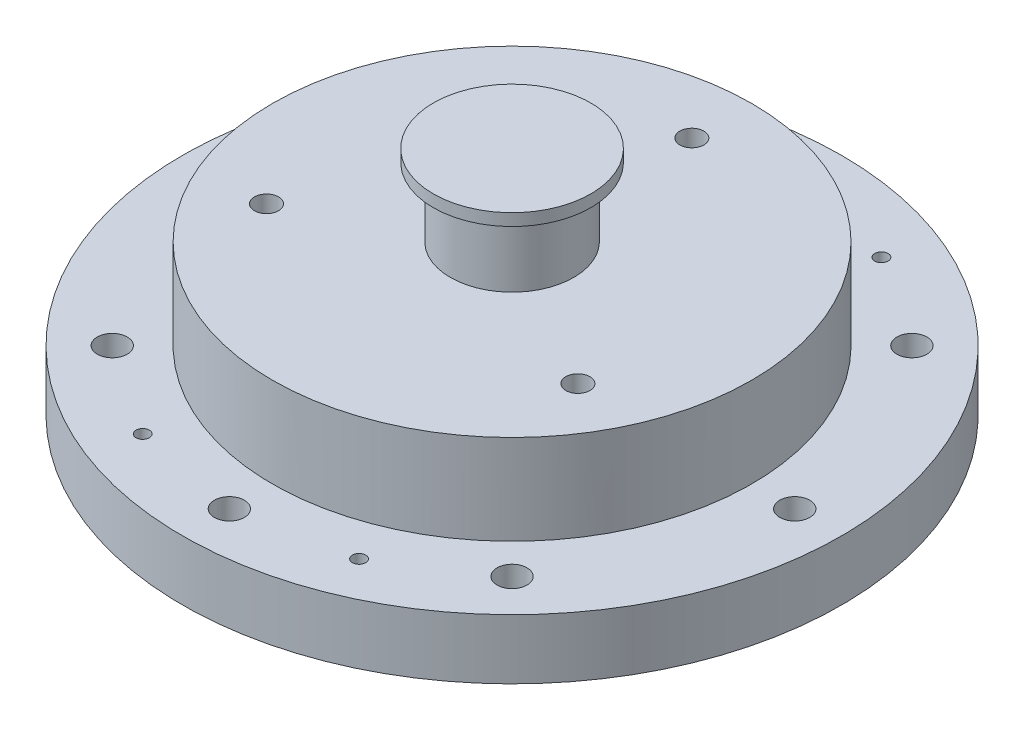
from build123d import *

# Parameters (mm, degrees)
SKETCH1_R                        = 50.8
BOSS_EXTRUDE1_DEPTH              = 25.4
SKETCH2_R                        = 69.85
SKETCH2_R_2                      = 50.8
BOSS_EXTRUDE2_DEPTH              = 12.7
CUT_EXTRUDE2_REACH               = 27.4
SKETCH4_R                        = 3.175
SKETCH5_R                        = 12.827
CUT_EXTRUDE3_DEPTH               = 19.05
CUT_EXTRUDE4_REACH               = 8.35
SKETCH6_R                        = 1.5875
SKETCH34_R                       = 13.081
SKETCH34_R_2                     = 4.7625
BOSS_EXTRUDE3_DEPTH              = 19.05
SKETCH40_R                       = 50.8
BOSS_EXTRUDE5_DEPTH              = 6.35
SKETCH38_R                       = 6.2484
BOSS_EXTRUDE4_DEPTH              = 1.905
SKETCH39_R                       = 4.7625
CUT_EXTRUDE7_DEPTH               = 6.35
SKETCH41_R                       = 4.7625
CUT_EXTRUDE8_DEPTH               = 6.35
SKETCH42_R                       = 23.7871
CUT_EXTRUDE9_DEPTH               = 6.477
F_10_24_TAPPED_HOLE1_AT_2_COUNT  = 2
F_10_24_TAPPED_HOLE1_AT_2_PITCH  = 24.695704333
F_10_24_TAPPED_HOLE1_AT_3_COUNT  = 2
F_10_24_TAPPED_HOLE1_AT_3_PITCH  = 34.925
F_10_24_TAPPED_HOLE1_AT_4_COUNT  = 2
F_10_24_TAPPED_HOLE1_AT_4_PITCH  = 24.695704333
SKETCH46_R                       = 3.175
CUT_EXTRUDE10_DEPTH              = 6.35
F_1_4_20_TAPPED_HOLE1_AT_2_COUNT = 2
F_1_4_20_TAPPED_HOLE1_AT_2_PITCH = 65.991135768
F_1_4_20_TAPPED_HOLE1_AT_3_COUNT = 2
F_1_4_20_TAPPED_HOLE1_AT_3_PITCH = 65.991135768
CUT_EXTRUDE11_START              = 6.477
SKETCH49_R                       = 23.8252
CUT_EXTRUDE11_DEPTH              = 3.937
SKETCH50_R                       = 1.4097
CUT_EXTRUDE12_DEPTH              = 41.005
SKETCH51_R                       = 16.693981068
BOSS_EXTRUDE6_DEPTH              = 2.54


with BuildPart() as part:
    # Sketch1 → Boss-Extrude1 (new body)
    with BuildSketch(Plane(origin=(0, 0, 0), x_dir=(1, 0, 0), z_dir=(0, 1, 0))):
        Circle(SKETCH1_R)
    extrude(amount=BOSS_EXTRUDE1_DEPTH)

    # Sketch2 → Boss-Extrude2 (add)
    with BuildSketch(Plane.XZ):
        Circle(SKETCH2_R)
        Circle(SKETCH2_R_2, mode=Mode.SUBTRACT)
    extrude(amount=-BOSS_EXTRUDE2_DEPTH)

    # Sketch4 → Cut-Extrude2 (cut, up to next)
    with BuildSketch(Plane.XZ, mode=Mode.PRIVATE) as cut_extrude2_sk1:
        with Locations((0, -59.9186)):
            Circle(SKETCH4_R)
    cut_extrude2_tool1 = extrude(cut_extrude2_sk1.sketch, amount=-CUT_EXTRUDE2_REACH, mode=Mode.PRIVATE) & part.part
    add(cut_extrude2_tool1.solids().sort_by_distance((0, 0, -59.9186))[0], mode=Mode.SUBTRACT)
    # Sketch4 → Cut-Extrude2 (cut, up to next)
    with BuildSketch(Plane.XZ, mode=Mode.PRIVATE) as cut_extrude2_sk2:
        with Locations((-42.368848379, -42.368848379)):
            Circle(SKETCH4_R)
    cut_extrude2_tool2 = extrude(cut_extrude2_sk2.sketch, amount=-CUT_EXTRUDE2_REACH, mode=Mode.PRIVATE) & part.part
    add(cut_extrude2_tool2.solids().sort_by_distance((-42.368848, 0, -42.368848))[0], mode=Mode.SUBTRACT)
    # Sketch4 → Cut-Extrude2 (cut, up to next)
    with BuildSketch(Plane.XZ, mode=Mode.PRIVATE) as cut_extrude2_sk3:
        with Locations((-59.9186, 0)):
            Circle(SKETCH4_R)
    cut_extrude2_tool3 = extrude(cut_extrude2_sk3.sketch, amount=-CUT_EXTRUDE2_REACH, mode=Mode.PRIVATE) & part.part
    add(cut_extrude2_tool3.solids().sort_by_distance((-59.9186, 0, 0))[0], mode=Mode.SUBTRACT)
    # Sketch4 → Cut-Extrude2 (cut, up to next)
    with BuildSketch(Plane.XZ, mode=Mode.PRIVATE) as cut_extrude2_sk4:
        with Locations((-42.368848379, 42.368848379)):
            Circle(SKETCH4_R)
    cut_extrude2_tool4 = extrude(cut_extrude2_sk4.sketch, amount=-CUT_EXTRUDE2_REACH, mode=Mode.PRIVATE) & part.part
    add(cut_extrude2_tool4.solids().sort_by_distance((-42.368848, 0, 42.368848))[0], mode=Mode.SUBTRACT)
    # Sketch4 → Cut-Extrude2 (cut, up to next)
    with BuildSketch(Plane.XZ, mode=Mode.PRIVATE) as cut_extrude2_sk5:
        with Locations((0, 59.9186)):
            Circle(SKETCH4_R)
    cut_extrude2_tool5 = extrude(cut_extrude2_sk5.sketch, amount=-CUT_EXTRUDE2_REACH, mode=Mode.PRIVATE) & part.part
    add(cut_extrude2_tool5.solids().sort_by_distance((0, 0, 59.9186))[0], mode=Mode.SUBTRACT)
    # Sketch4 → Cut-Extrude2 (cut, up to next)
    with BuildSketch(Plane.XZ, mode=Mode.PRIVATE) as cut_extrude2_sk6:
        with Locations((42.368848379, 42.368848379)):
            Circle(SKETCH4_R)
    cut_extrude2_tool6 = extrude(cut_extrude2_sk6.sketch, amount=-CUT_EXTRUDE2_REACH, mode=Mode.PRIVATE) & part.part
    add(cut_extrude2_tool6.solids().sort_by_distance((42.368848, 0, 42.368848))[0], mode=Mode.SUBTRACT)
    # Sketch4 → Cut-Extrude2 (cut, up to next)
    with BuildSketch(Plane.XZ, mode=Mode.PRIVATE) as cut_extrude2_sk7:
        with Locations((59.9186, 0)):
            Circle(SKETCH4_R)
    cut_extrude2_tool7 = extrude(cut_extrude2_sk7.sketch, amount=-CUT_EXTRUDE2_REACH, mode=Mode.PRIVATE) & part.part
    add(cut_extrude2_tool7.solids().sort_by_distance((59.9186, 0, 0))[0], mode=Mode.SUBTRACT)
    # Sketch4 → Cut-Extrude2 (cut, up to next)
    with BuildSketch(Plane.XZ, mode=Mode.PRIVATE) as cut_extrude2_sk8:
        with Locations((42.368848379, -42.368848379)):
            Circle(SKETCH4_R)
    cut_extrude2_tool8 = extrude(cut_extrude2_sk8.sketch, amount=-CUT_EXTRUDE2_REACH, mode=Mode.PRIVATE) & part.part
    add(cut_extrude2_tool8.solids().sort_by_distance((42.368848, 0, -42.368848))[0], mode=Mode.SUBTRACT)

    # Sketch5 → Cut-Extrude3 (cut)
    with BuildSketch(Plane(origin=(0, 25.4, 0), x_dir=(1, 0, 0), z_dir=(0, 1, 0))):
        Circle(SKETCH5_R)
    extrude(amount=-CUT_EXTRUDE3_DEPTH, mode=Mode.SUBTRACT)

    # Sketch6 → Cut-Extrude4 (cut, up to next)
    with BuildSketch(Plane(origin=(0, 6.35, 0), x_dir=(1, 0, 0), z_dir=(0, 1, 0)), mode=Mode.PRIVATE) as cut_extrude4_sk1:
        Circle(SKETCH6_R)
    cut_extrude4_tool1 = extrude(cut_extrude4_sk1.sketch, amount=-CUT_EXTRUDE4_REACH, mode=Mode.PRIVATE) & part.part
    add(cut_extrude4_tool1.solids().sort_by_distance((0, 6.35, 0))[0], mode=Mode.SUBTRACT)

    # Sketch34 → Boss-Extrude3 (add)
    with BuildSketch(Plane(origin=(0, 25.4, 0), x_dir=(1, 0, 0), z_dir=(0, 1, 0))):
        Circle(SKETCH34_R)
        Circle(SKETCH34_R_2, mode=Mode.SUBTRACT)
    extrude(amount=BOSS_EXTRUDE3_DEPTH)

    # Sketch40 → Boss-Extrude5 (add)
    with BuildSketch(Plane(origin=(0, 25.4, 0), x_dir=(1, 0, 0), z_dir=(0, 1, 0))):
        Circle(SKETCH40_R)
    extrude(amount=BOSS_EXTRUDE5_DEPTH)

    # Sketch41 → Cut-Extrude8 (cut)
    with BuildSketch(Plane(origin=(0, 31.75, 0), x_dir=(1, 0, 0), z_dir=(0, 1, 0))):
        Circle(SKETCH41_R)
    extrude(amount=-CUT_EXTRUDE8_DEPTH, mode=Mode.SUBTRACT)

    # Sketch42 → Cut-Extrude9 (cut)
    with BuildSketch(Plane.XZ):
        Circle(SKETCH42_R)
    extrude(amount=-CUT_EXTRUDE9_DEPTH, mode=Mode.SUBTRACT)

    # Sketch45 → #10-24 Tapped Hole1 (revolve, cut)
    with BuildSketch(Plane(origin=(0, 6.477, 17.4625), x_dir=(0, 0, -1), z_dir=(1, 0, 0))):
        Polygon((0, 0), (0, 13.840824014), (1.89865, 12.7), (1.89865, 0), align=None)
    f_10_24_tapped_hole1 = revolve(axis=Axis((0, 0.127, 17.4625), (0, 1, 0)), mode=Mode.SUBTRACT)

    # #10-24 Tapped Hole1 at 2: #10-24 Tapped Hole1 ×2
    with Locations(*[Vector(0.707106781, 0, -0.707106781) * (i * F_10_24_TAPPED_HOLE1_AT_2_PITCH) for i in range(1, F_10_24_TAPPED_HOLE1_AT_2_COUNT)]):
        add(f_10_24_tapped_hole1, mode=Mode.SUBTRACT)

    # #10-24 Tapped Hole1 at 3: #10-24 Tapped Hole1 ×2
    with Locations(*[(0, 0, -i * F_10_24_TAPPED_HOLE1_AT_3_PITCH) for i in range(1, F_10_24_TAPPED_HOLE1_AT_3_COUNT)]):
        add(f_10_24_tapped_hole1, mode=Mode.SUBTRACT)

    # #10-24 Tapped Hole1 at 4: #10-24 Tapped Hole1 ×2
    with Locations(*[Vector(-0.707106781, 0, -0.707106781) * (i * F_10_24_TAPPED_HOLE1_AT_4_PITCH) for i in range(1, F_10_24_TAPPED_HOLE1_AT_4_COUNT)]):
        add(f_10_24_tapped_hole1, mode=Mode.SUBTRACT)

    # Sketch46 → Cut-Extrude10 (cut)
    with BuildSketch(Plane.XZ):
        with Locations((-22.929855511, 55.357568157)):
            Circle(SKETCH46_R)
        with Locations((22.929855511, 55.357568157)):
            Circle(SKETCH46_R)
        with Locations((-22.929855511, -55.357568157)):
            Circle(SKETCH46_R)
        with Locations((22.929855511, -55.357568157)):
            Circle(SKETCH46_R)
    extrude(amount=-CUT_EXTRUDE10_DEPTH, mode=Mode.SUBTRACT)

    # Sketch48 → 1/4-20 Tapped Hole1 (revolve, cut)
    with BuildSketch(Plane(origin=(0, 31.75, -38.1), x_dir=(0, 0, 1), z_dir=(1, 0, 0))):
        Polygon((0, 0), (0, 15.503816902), (2.5527, 13.97), (2.5527, 0), align=None)
    f_1_4_20_tapped_hole1 = revolve(axis=Axis((0, 38.1, -38.1), (0, -1, 0)), mode=Mode.SUBTRACT)

    # 1/4-20 Tapped Hole1 at 2: 1/4-20 Tapped Hole1 ×2
    with Locations(*[Vector(0.5, 0, 0.866025404) * (i * F_1_4_20_TAPPED_HOLE1_AT_2_PITCH) for i in range(1, F_1_4_20_TAPPED_HOLE1_AT_2_COUNT)]):
        add(f_1_4_20_tapped_hole1, mode=Mode.SUBTRACT)

    # 1/4-20 Tapped Hole1 at 3: 1/4-20 Tapped Hole1 ×2
    with Locations(*[Vector(-0.5, 0, 0.866025404) * (i * F_1_4_20_TAPPED_HOLE1_AT_3_PITCH) for i in range(1, F_1_4_20_TAPPED_HOLE1_AT_3_COUNT)]):
        add(f_1_4_20_tapped_hole1, mode=Mode.SUBTRACT)

    # Sketch49 → Cut-Extrude11 (cut)
    with BuildSketch(Plane.XZ.offset(-6.477).offset(CUT_EXTRUDE11_START)):
        Circle(SKETCH49_R)
    extrude(amount=-CUT_EXTRUDE11_DEPTH, mode=Mode.SUBTRACT)

    # Sketch50 → Cut-Extrude12 (cut, through all)
    with BuildSketch(Plane.XZ.offset(-6.35)):
        with Locations((-22.929855511, 55.357568157)):
            Circle(SKETCH50_R)
        with Locations((22.929855511, 55.357568157)):
            Circle(SKETCH50_R)
        with Locations((-22.929855511, -55.357568157)):
            Circle(SKETCH50_R)
        with Locations((22.929855511, -55.357568157)):
            Circle(SKETCH50_R)
    extrude(amount=-CUT_EXTRUDE12_DEPTH, mode=Mode.SUBTRACT)


with BuildPart() as body_2:
    # Sketch38 → Boss-Extrude4 (new body)
    with BuildSketch(Plane(origin=(0, 44.45, 0), x_dir=(1, 0, 0), z_dir=(0, 1, 0))):
        Circle(SKETCH38_R)
    extrude(amount=BOSS_EXTRUDE4_DEPTH)

    # Sketch39 → Cut-Extrude7 (cut)
    with BuildSketch(Plane(origin=(0, 46.355, 0), x_dir=(1, 0, 0), z_dir=(0, 1, 0))):
        Circle(SKETCH39_R)
    extrude(amount=-CUT_EXTRUDE7_DEPTH, mode=Mode.SUBTRACT)

    # Sketch51 → Boss-Extrude6 (add)
    with BuildSketch(Plane(origin=(0, 46.355, 0), x_dir=(1, 0, 0), z_dir=(0, 1, 0))):
        Circle(SKETCH51_R)
    extrude(amount=BOSS_EXTRUDE6_DEPTH)


solid = Compound([part.part, body_2.part])
